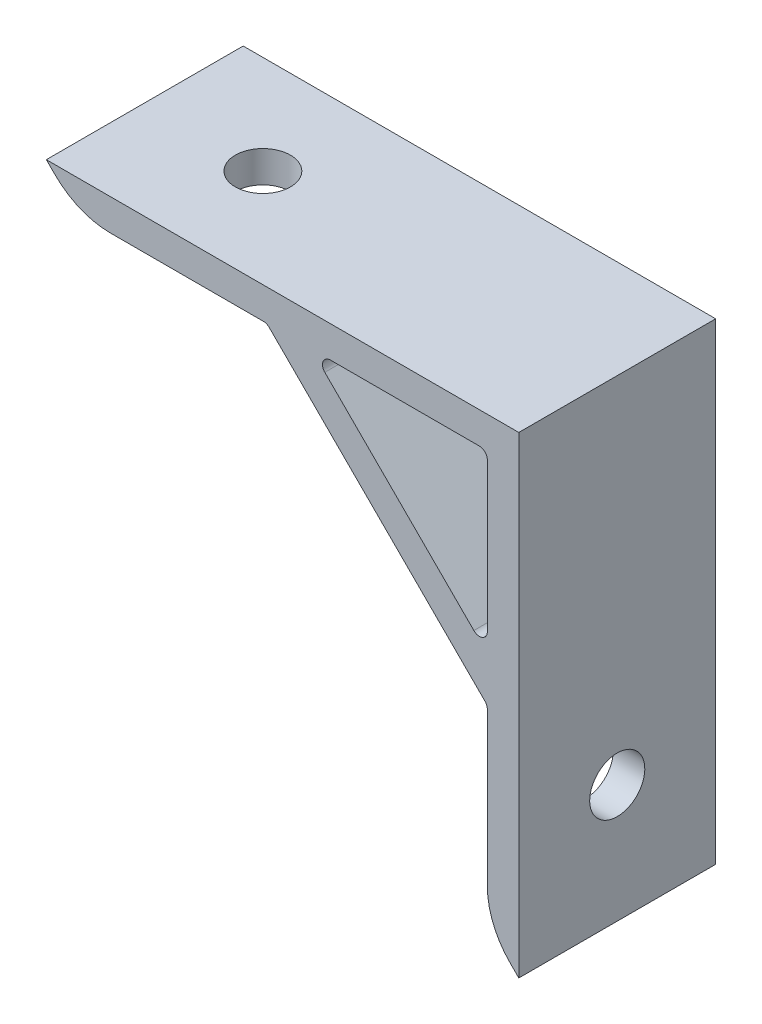
from build123d import *

# Parameters (mm, degrees)
EXTRUDE_1_DEPTH     = 25
FILLET_1_R          = 10
FILLET_2_R          = 1
SKETCH_2_R          = 3.5
CUT_EXTRUDE_2_DEPTH = 25
SKETCH_4_R          = 3.5
CUT_EXTRUDE_3_DEPTH = 25


with BuildPart() as part:
    # 스케치1 → 보스-돌출1 (new body)
    with BuildSketch(Plane.XY):
        Polygon((-30, 30), (30, 30), (30, -30), (26, -26), (26, -2), (-2, 26), (-26, 26), align=None)
        Polygon((26, 26), (26, 3.656854249), (3.656854249, 26), align=None, mode=Mode.SUBTRACT)
    extrude(amount=EXTRUDE_1_DEPTH)

    # 필렛1
    fillet_1_edges = [part.edges().sort_by_distance(p)[0] for p in [
        (26, -26, 12.5),
        (-26, 26, 12.5),
    ]]
    fillet(fillet_1_edges, radius=FILLET_1_R)

    # 필렛2
    fillet_2_edges = [part.edges().sort_by_distance(p)[0] for p in [
        (26, -2, 12.5),
        (-2, 26, 12.5),
        (26, 26, 12.5),
        (3.656854249, 26, 12.5),
        (26, 3.656854249, 12.5),
    ]]
    fillet(fillet_2_edges, radius=FILLET_2_R)

    # 스케치2 → 컷-돌출2 (cut)
    with BuildSketch(Plane(origin=(0, 30, 0), x_dir=(1, 0, 0), z_dir=(0, 1, 0))):
        with Locations((-15, -12.5)):
            Circle(SKETCH_2_R)
    extrude(amount=-CUT_EXTRUDE_2_DEPTH, mode=Mode.SUBTRACT)

    # 스케치4 → 컷-돌출3 (cut)
    with BuildSketch(Plane(origin=(30, 0, 0), x_dir=(0, 0, -1), z_dir=(1, 0, 0))):
        with Locations((-12.5, -15)):
            Circle(SKETCH_4_R)
    extrude(amount=-CUT_EXTRUDE_3_DEPTH, mode=Mode.SUBTRACT)


solid = part.part
